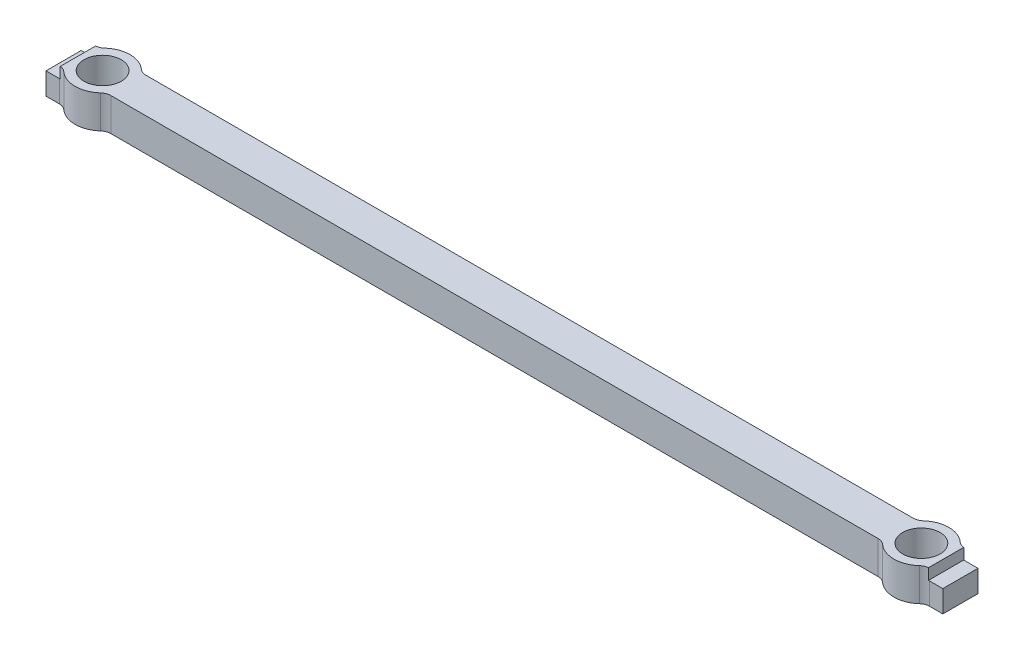
from build123d import *

# Parameters (mm, degrees)
SKETCH1_R       = 1.7
SHAPE_DEPTH     = 3
MILL_FILLETS_R  = 1
EDGE_CUTS_DEPTH = 1


with BuildPart() as part:
    # Sketch1 → Shape (new body)
    with BuildSketch(Plane(origin=(0, 0, 0), x_dir=(1, 0, 0), z_dir=(0, 1, 0))):
        with BuildLine():
            Line((-35.329062729, -1.6), (35.329062729, -1.6))
            ThreePointArc((35.329062729, -1.6), (37.25, -2.5), (39.170937271, -1.6))
            Line((39.170937271, -1.6), (40.8, -1.6))
            Line((40.8, -1.6), (40.8, 1.6))
            Line((40.8, 1.6), (39.170937271, 1.6))
            ThreePointArc((39.170937271, 1.6), (37.25, 2.5), (35.329062729, 1.6))
            Line((35.329062729, 1.6), (-35.329062729, 1.6))
            ThreePointArc((-35.329062729, 1.6), (-37.25, 2.5), (-39.170937271, 1.6))
            Line((-39.170937271, 1.6), (-40.8, 1.6))
            Line((-40.8, 1.6), (-40.8, -1.6))
            Line((-40.8, -1.6), (-39.170937271, -1.6))
            ThreePointArc((-39.170937271, -1.6), (-37.25, -2.5), (-35.329062729, -1.6))
        make_face()
        with Locations((37.25, 0)):
            Circle(SKETCH1_R, mode=Mode.SUBTRACT)
        with Locations((-37.25, 0)):
            Circle(SKETCH1_R, mode=Mode.SUBTRACT)
    extrude(amount=SHAPE_DEPTH)

    # Mill fillets
    mill_fillets_edges = [part.edges().sort_by_distance(p)[0] for p in [
        (-35.329062729, 1.5, -1.6),
        (35.329062729, 1.5, -1.6),
        (39.170937271, 1.5, -1.6),
        (39.170937271, 1.5, 1.6),
        (35.329062729, 1.5, 1.6),
        (-35.329062729, 1.5, 1.6),
        (-39.170937271, 1.5, 1.6),
        (-39.170937271, 1.5, -1.6),
    ]]
    fillet(mill_fillets_edges, radius=MILL_FILLETS_R)

    # Sketch2 → Edge cuts (cut)
    with BuildSketch(Plane(origin=(0, 3, 0), x_dir=(1, 0, 0), z_dir=(0, 1, 0))):
        with BuildLine():
            Line((-39.5, -1.60434089), (-39.5, 1.60434089))
            ThreePointArc((-39.5, 1.60434089), (-39.546486866, 1.601085812), (-39.593074903, 1.6))
            Line((-39.593074903, 1.6), (-40.8, 1.6))
            Line((-40.8, 1.6), (-40.8, -1.6))
            Line((-40.8, -1.6), (-39.593074903, -1.6))
            ThreePointArc((-39.593074903, -1.6), (-39.546486866, -1.601085812), (-39.5, -1.60434089))
        make_face()
        with BuildLine():
            ThreePointArc((39.593074903, 1.6), (39.546486866, 1.601085812), (39.5, 1.60434089))
            Line((39.5, 1.60434089), (39.5, -1.60434089))
            ThreePointArc((39.5, -1.60434089), (39.546486866, -1.601085812), (39.593074903, -1.6))
            Line((39.593074903, -1.6), (40.8, -1.6))
            Line((40.8, -1.6), (40.8, 1.6))
            Line((40.8, 1.6), (39.593074903, 1.6))
        make_face()
    extrude(amount=-EDGE_CUTS_DEPTH, mode=Mode.SUBTRACT)


solid = part.part
